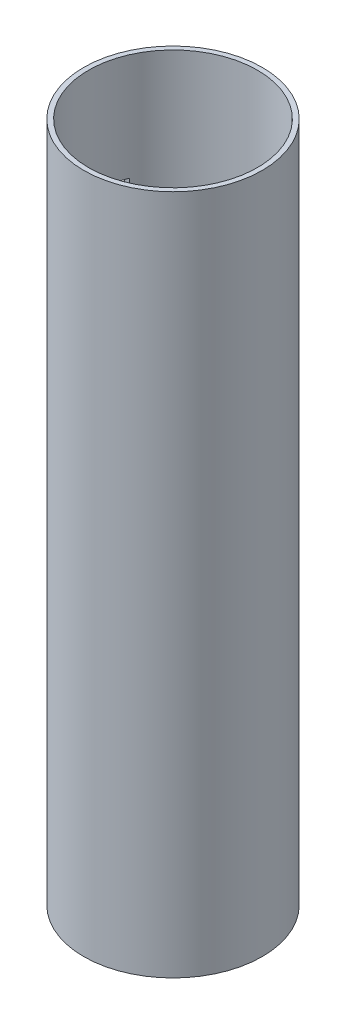
from build123d import *

# Parameters (mm, degrees)
SKETCH1_R           = 47.084225238
BOSS_EXTRUDE1_DEPTH = 359.156
SHELL1_T            = -2.54
SKETCH2_W           = 31.043805041
SKETCH2_H           = 64.909774176
CUT_EXTRUDE1_DEPTH  = 359.156


with BuildPart() as part:
    # Sketch1 → Boss-Extrude1 (new body)
    with BuildSketch(Plane(origin=(0, 0, 0), x_dir=(1, 0, 0), z_dir=(0, 1, 0))):
        with Locations(Location((0, 0, 0), (0, 0, 270))):
            Circle(SKETCH1_R)
    extrude(amount=BOSS_EXTRUDE1_DEPTH)

    # Shell1
    shell1_openings = [part.faces().sort_by_distance(p)[0] for p in [
        (0, 359.156, 0),
        (0, 0, 0),
    ]]
    offset(amount=SHELL1_T, openings=shell1_openings, kind=Kind.INTERSECTION)

    # Sketch2 → Cut-Extrude1 (cut)
    with BuildSketch(Plane(origin=(0, 0, 0), x_dir=(0, 0, -1), z_dir=(1, 0, 0))):
        with Locations((2.351803412, 270.240021539)):
            Rectangle(SKETCH2_W, SKETCH2_H)
    extrude(amount=-CUT_EXTRUDE1_DEPTH, mode=Mode.SUBTRACT)


solid = part.part
